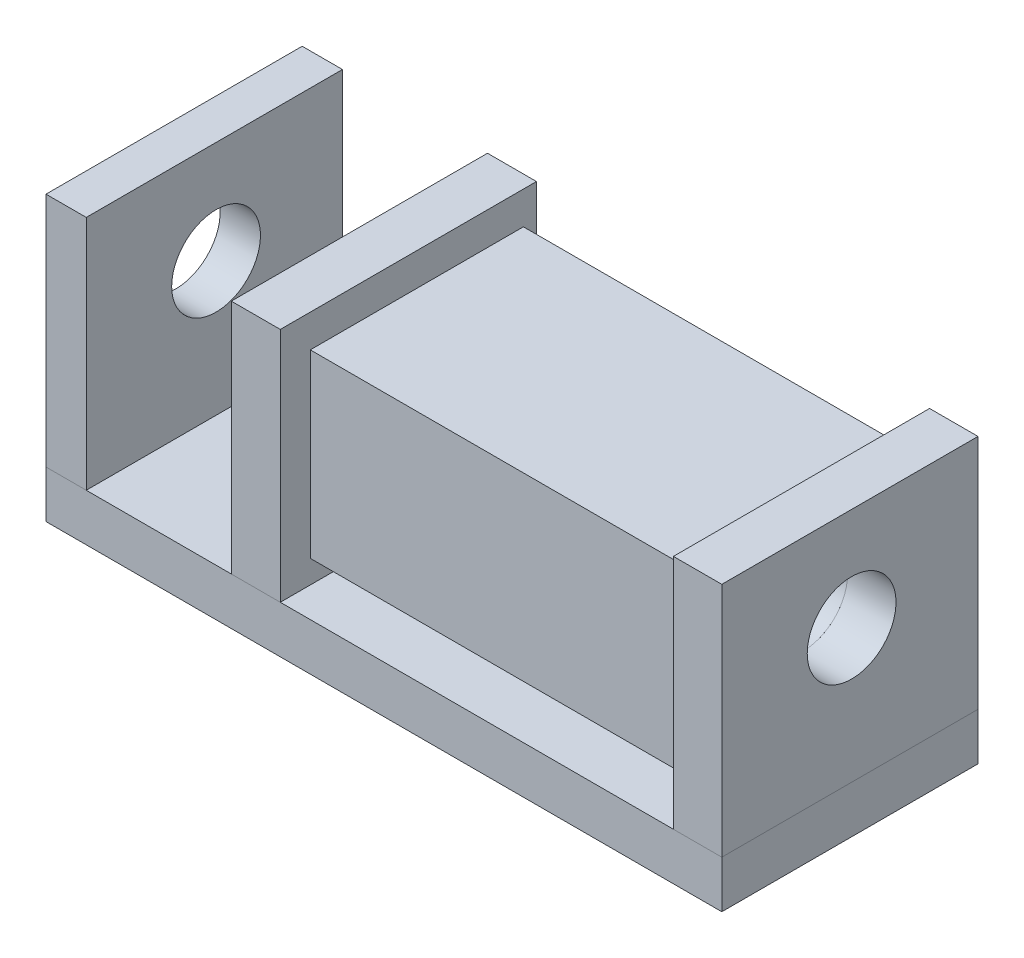
from build123d import *

# Parameters (mm, degrees)
SKIZZE1_W                         = 142.992898016
SKIZZE1_H                         = 54.206458071
AUFSATZ_LINEAR_AUSTRAGEN1_DEPTH   = 10
SKIZZE2_W                         = 8.518727461
SKIZZE2_H                         = 54.206458071
AUFSATZ_LINEAR_AUSTRAGEN2_DEPTH   = 50
SKIZZE2_W_2                       = 10.24596455
AUFSATZ_LINEAR_AUSTRAGEN2_2_DEPTH = 50
SKIZZE3_W                         = 10.363422534
SKIZZE3_H                         = 54.206458071
AUFSATZ_LINEAR_AUSTRAGEN3_DEPTH   = 50
SKIZZE4_W                         = 45.089308898
SKIZZE4_H                         = 38.205008477
OPTIONAL_DEPTH                    = 83.173109
SKIZZE5_R                         = 9.391884554
SCHNITT_LINEAR_AUSTRAGEN1_DEPTH   = 142.992898


with BuildPart() as part:
    # Skizze1 → Aufsatz-Linear austragen1 (new body)
    with BuildSketch(Plane(origin=(0, 0, 0), x_dir=(1, 0, 0), z_dir=(0, 1, 0))):
        with Locations((71.496449008, 27.103229036)):
            Rectangle(SKIZZE1_W, SKIZZE1_H)
    extrude(amount=AUFSATZ_LINEAR_AUSTRAGEN1_DEPTH)


with BuildPart() as body_2:
    # Skizze2 → Aufsatz-Linear austragen2 (new body)
    with BuildSketch(Plane(origin=(0, 10, 0), x_dir=(1, 0, 0), z_dir=(0, 1, 0))):
        with Locations((4.259363731, 27.103229036)):
            Rectangle(SKIZZE2_W, SKIZZE2_H)
    extrude(amount=AUFSATZ_LINEAR_AUSTRAGEN2_DEPTH)


with BuildPart() as body_3:
    # Skizze2 → Aufsatz-Linear austragen2 2 (new body)
    with BuildSketch(Plane(origin=(0, 10, 0), x_dir=(1, 0, 0), z_dir=(0, 1, 0))):
        with Locations((137.869915741, 27.103229036)):
            Rectangle(SKIZZE2_W_2, SKIZZE2_H)
    extrude(amount=AUFSATZ_LINEAR_AUSTRAGEN2_2_DEPTH)


with BuildPart() as body_4:
    # Skizze3 → Aufsatz-Linear austragen3 (new body)
    with BuildSketch(Plane(origin=(0, 10, 0), x_dir=(1, 0, 0), z_dir=(0, 1, 0))):
        with Locations((44.392113152, 27.103229036)):
            Rectangle(SKIZZE3_W, SKIZZE3_H)
    extrude(amount=AUFSATZ_LINEAR_AUSTRAGEN3_DEPTH)


with BuildPart() as body_5:
    # Skizze4 → Optional (new body)
    with BuildSketch(Plane(origin=(49.573824419, 0, 0), x_dir=(0, 0, -1), z_dir=(1, 0, 0))):
        with Locations((28.892468722, 33.979452593)):
            Rectangle(SKIZZE4_W, SKIZZE4_H)
    extrude(amount=OPTIONAL_DEPTH)


with BuildPart() as schnitt_linear_austragen1_tool:
    # Skizze5 → Schnitt-Linear austragen1 (new body)
    with BuildSketch(Plane.ZY):
        with Locations(Location((-27.463964756, 38.296921572, 0), (0, 0, 180))):  # turned: the seam where the file's is
            Circle(SKIZZE5_R)
    extrude(amount=-SCHNITT_LINEAR_AUSTRAGEN1_DEPTH)


with BuildPart() as body_2_1:
    add(body_2.part)

    # Schnitt-Linear austragen1: cut by schnitt_linear_austragen1_tool
    add(schnitt_linear_austragen1_tool.part, mode=Mode.SUBTRACT)


with BuildPart() as body_3_1:
    add(body_3.part)

    # Schnitt-Linear austragen1: cut by schnitt_linear_austragen1_tool
    add(schnitt_linear_austragen1_tool.part, mode=Mode.SUBTRACT)


with BuildPart() as body_4_1:
    add(body_4.part)

    # Schnitt-Linear austragen1: cut by schnitt_linear_austragen1_tool
    add(schnitt_linear_austragen1_tool.part, mode=Mode.SUBTRACT)


with BuildPart() as body_5_1:
    add(body_5.part)

    # Schnitt-Linear austragen1: cut by schnitt_linear_austragen1_tool
    add(schnitt_linear_austragen1_tool.part, mode=Mode.SUBTRACT)


solid = Compound([part.part, body_2_1.part, body_3_1.part, body_4_1.part, body_5_1.part])
